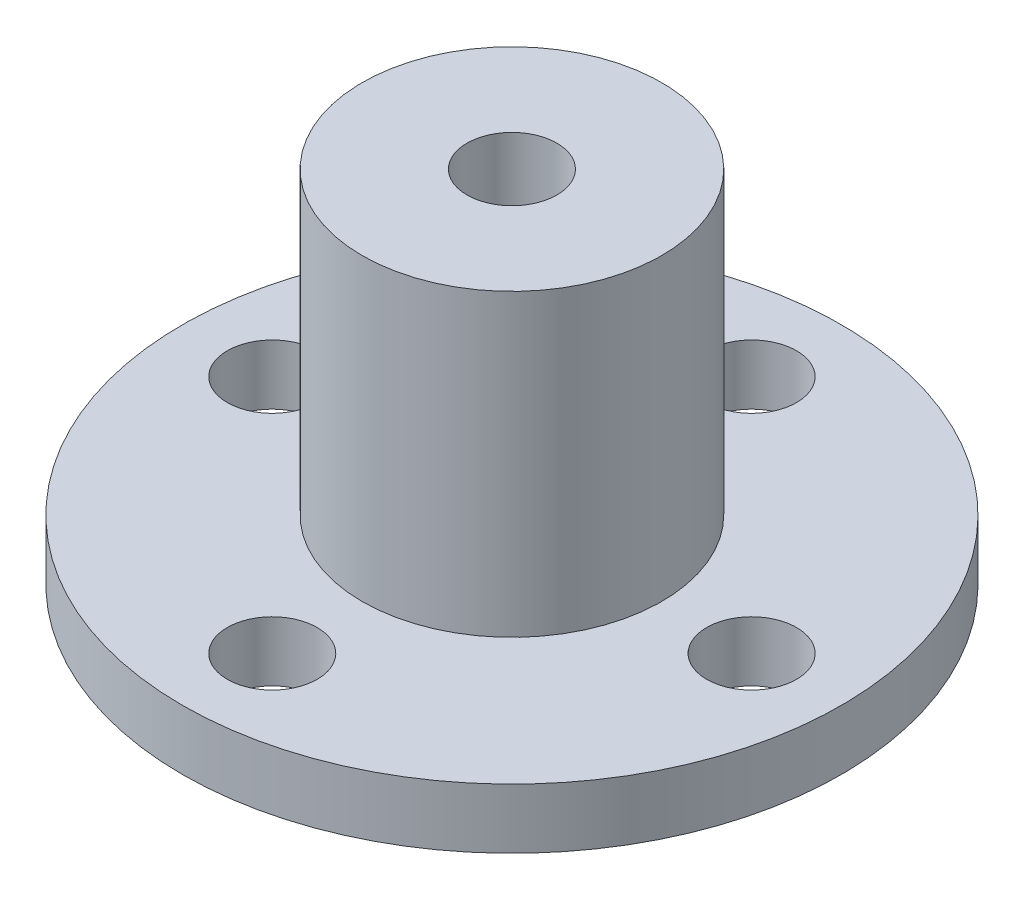
from build123d import *

# Parameters (mm, degrees)
SKETCH1_R           = 11
SKETCH1_R_2         = 1.5
SKETCH1_R_3         = 5
BOSS_EXTRUDE1_DEPTH = 2
SKETCH1_3_R         = 5
BOSS_EXTRUDE2_DEPTH = 12
SKETCH2_R           = 1.5
CUT_EXTRUDE1_DEPTH  = 10


with BuildPart() as part:
    # Sketch1 → Boss-Extrude1 (new body)
    with BuildSketch(Plane(origin=(0, 0, 0), x_dir=(1, 0, 0), z_dir=(0, 1, 0))):
        Circle(SKETCH1_R)
        with Locations((0, -8)):
            Circle(SKETCH1_R_2, mode=Mode.SUBTRACT)
        with Locations((-8, 0)):
            Circle(SKETCH1_R_2, mode=Mode.SUBTRACT)
        Circle(SKETCH1_R_3, mode=Mode.SUBTRACT)
        with BuildLine():
            ThreePointArc((6.5, 0), (8, 1.5), (9.5, 0))
            ThreePointArc((9.5, 0), (8, -1.5), (6.5, 0))
        make_face(mode=Mode.SUBTRACT)
        with Locations((0, 8)):
            Circle(SKETCH1_R_2, mode=Mode.SUBTRACT)
    extrude(amount=BOSS_EXTRUDE1_DEPTH)

    # Sketch1_3 → Boss-Extrude2 (add)
    with BuildSketch(Plane(origin=(0, 0, 0), x_dir=(1, 0, 0), z_dir=(0, 1, 0))):
        Circle(SKETCH1_3_R)
    extrude(amount=BOSS_EXTRUDE2_DEPTH)

    # Sketch2 → Cut-Extrude1 (cut)
    with BuildSketch(Plane(origin=(0, 12, 0), x_dir=(1, 0, 0), z_dir=(0, 1, 0))):
        Circle(SKETCH2_R)
    extrude(amount=-CUT_EXTRUDE1_DEPTH, mode=Mode.SUBTRACT)


solid = part.part
